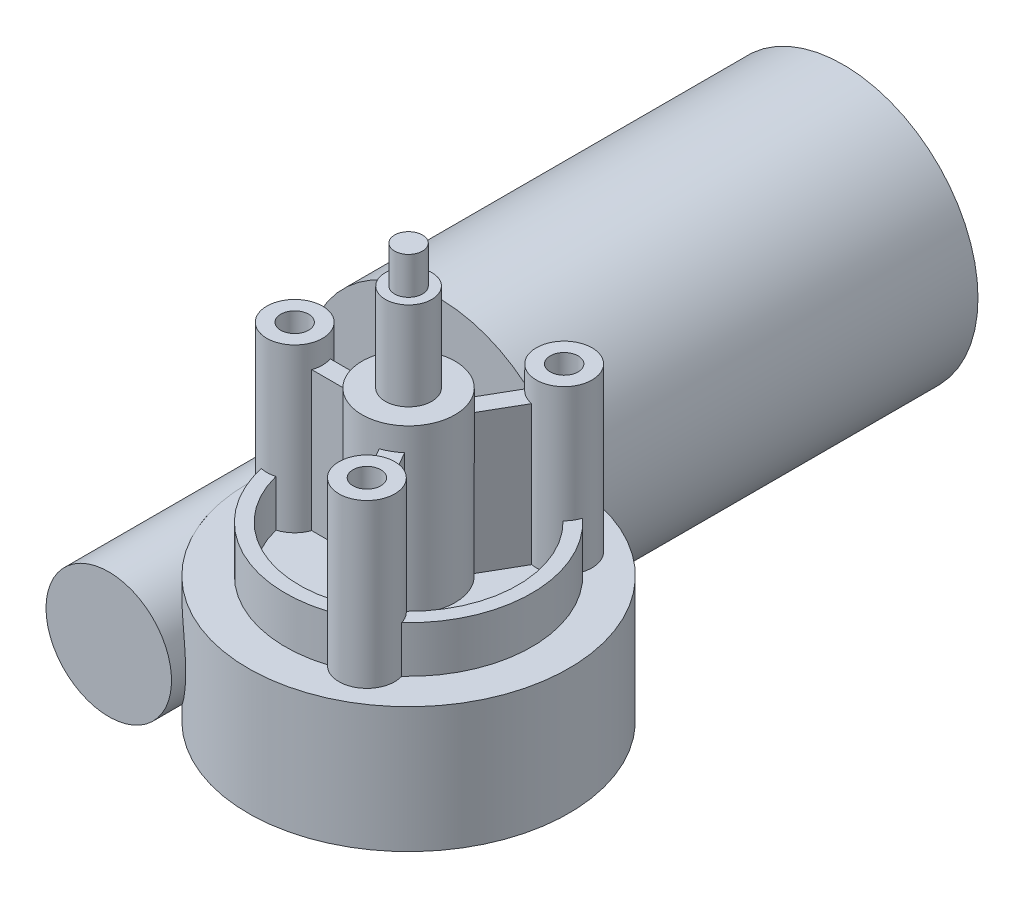
from build123d import *

# Parameters (mm, degrees)
SKETCH1_R           = 29
BOSS_EXTRUDE1_DEPTH = 87
SKETCH3_W           = 13.5
SKETCH3_H           = 168
SKETCH4_R           = 34.5
BOSS_EXTRUDE2_DEPTH = 13.5
SKETCH5_R           = 6
SKETCH5_R_2         = 10
BOSS_EXTRUDE3_DEPTH = 35
BOSS_EXTRUDE4_DEPTH = 30
SKETCH7_R           = 26.5
SKETCH7_R_2         = 23.5
BOSS_EXTRUDE5_DEPTH = 10
SKETCH8_R           = 3
CUT_EXTRUDE1_DEPTH  = 18
SKETCH9_R           = 5
BOSS_EXTRUDE6_DEPTH = 19
SKETCH10_R          = 3
BOSS_EXTRUDE7_DEPTH = 8


with BuildPart() as part:
    # Sketch1 → Boss-Extrude1 (new body)
    with BuildSketch(Plane.XY):
        Circle(SKETCH1_R)
    extrude(amount=BOSS_EXTRUDE1_DEPTH)

    # Sketch3 → Revolve1 (revolve)
    with BuildSketch(Plane(origin=(0, 0, 0), x_dir=(1, 0, 0), z_dir=(0, 1, 0))):
        with Locations((-6.75, -74)):
            Rectangle(SKETCH3_W, SKETCH3_H)
    revolve(axis=Axis((0, 0, 0), (0, 0, 1)))

    # Sketch4 → Boss-Extrude2 (add, symmetric)
    with BuildSketch(Plane(origin=(0, 0, 0), x_dir=(1, 0, 0), z_dir=(0, 1, 0))):
        with Locations((33, -126.5)):
            Circle(SKETCH4_R)
    extrude(amount=BOSS_EXTRUDE2_DEPTH, both=True)

    # Sketch5 → Boss-Extrude3 (add)
    with BuildSketch(Plane(origin=(0, 13.5, 0), x_dir=(1, 0, 0), z_dir=(0, 1, 0))):
        with Locations((8.5, -126.5)):
            Circle(SKETCH5_R)
        with Locations((33, -126.5)):
            Circle(SKETCH5_R_2)
        with Locations((45.25, -105.282377607)):
            Circle(SKETCH5_R)
        with Locations((45.25, -147.717622393)):
            Circle(SKETCH5_R)
    extrude(amount=BOSS_EXTRUDE3_DEPTH)

    # Sketch6 → Boss-Extrude4 (add)
    with BuildSketch(Plane(origin=(0, 13.5, 0), x_dir=(1, 0, 0), z_dir=(0, 1, 0))):
        Polygon((31.845299462, -128.5), (2.843145751, -128.5), (2.843145751, -124.5), (31.845299462, -124.5), (46.346376317, -99.383398122), (49.810477932, -101.383398122), (36.0121545, -125.282795366), (36.116305102, -127.897598768), (49.810477932, -151.616601878), (46.346376317, -153.616601878), align=None)
    extrude(amount=BOSS_EXTRUDE4_DEPTH)

    # Sketch7 → Boss-Extrude5 (add)
    with BuildSketch(Plane(origin=(0, 13.5, 0), x_dir=(1, 0, 0), z_dir=(0, 1, 0))):
        with Locations((33, -126.5)):
            Circle(SKETCH7_R)
        with Locations((33, -126.5)):
            Circle(SKETCH7_R_2, mode=Mode.SUBTRACT)
    extrude(amount=BOSS_EXTRUDE5_DEPTH)

    # Sketch8 → Cut-Extrude1 (cut)
    with BuildSketch(Plane(origin=(0, 48.5, 0), x_dir=(1, 0, 0), z_dir=(0, 1, 0))):
        with Locations((8.5, -126.5)):
            Circle(SKETCH8_R)
        with Locations((45.25, -105.282377607)):
            Circle(SKETCH8_R)
        with Locations((45.25, -147.717622393)):
            Circle(SKETCH8_R)
    extrude(amount=-CUT_EXTRUDE1_DEPTH, mode=Mode.SUBTRACT)

    # Sketch9 → Boss-Extrude6 (add)
    with BuildSketch(Plane(origin=(0, 48.5, 0), x_dir=(1, 0, 0), z_dir=(0, 1, 0))):
        with Locations((33, -126.5)):
            Circle(SKETCH9_R)
    extrude(amount=BOSS_EXTRUDE6_DEPTH)

    # Sketch10 → Boss-Extrude7 (add)
    with BuildSketch(Plane(origin=(0, 67.5, 0), x_dir=(1, 0, 0), z_dir=(0, 1, 0))):
        with Locations((33, -126.5)):
            Circle(SKETCH10_R)
    extrude(amount=BOSS_EXTRUDE7_DEPTH)


solid = part.part
